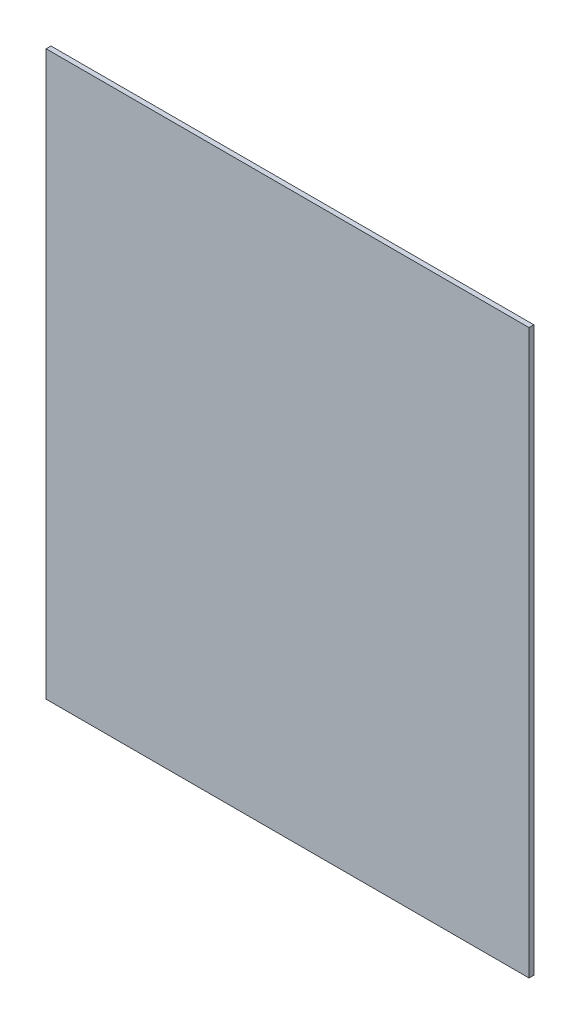
from build123d import *

# Parameters (mm, degrees)
ESQUISSE1_W        = 300
ESQUISSE1_H        = 350
BOSS_EXTRU_1_DEPTH = 3


with BuildPart() as part:
    # Esquisse1 → Boss.-Extru.1 (new body)
    with BuildSketch(Plane.XY):
        with Locations((150, 175)):
            Rectangle(ESQUISSE1_W, ESQUISSE1_H)
    extrude(amount=BOSS_EXTRU_1_DEPTH)


solid = part.part
